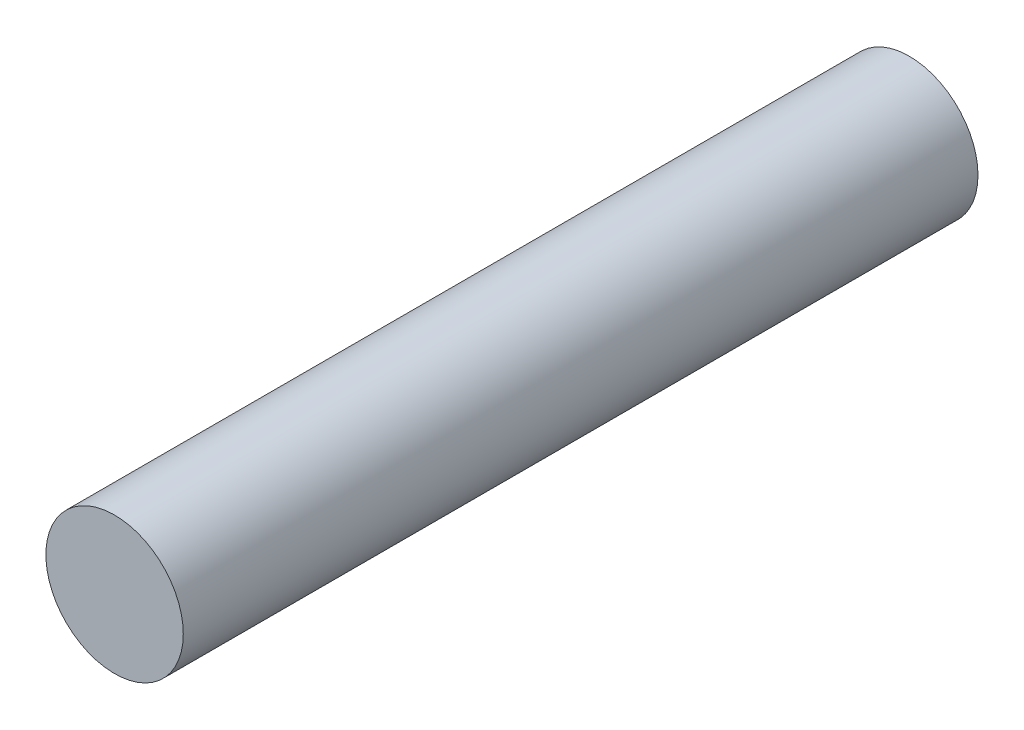
from build123d import *

# Parameters (mm, degrees)
SKETCH1_R                = 155
BOSS_EXTRUDE1_DEPTH      = 627
BOSS_EXTRUDE1_DEPTH_BACK = 1165.918189273
SCALE1_SCALE             = 0.3


with BuildPart() as part:
    # Sketch1 → Boss-Extrude1 (new body, two sides)
    with BuildSketch(Plane.XY) as boss_extrude1_sk:
        Circle(SKETCH1_R)
    extrude(amount=BOSS_EXTRUDE1_DEPTH)
    extrude(boss_extrude1_sk.sketch, amount=-BOSS_EXTRUDE1_DEPTH_BACK)


with BuildPart() as part_1:
    # Scale1: scaled about (0, 0, -269.459094637)
    add(part.part.scale(SCALE1_SCALE).moved(Location((0, 0, -188.621366246))))


solid = part_1.part
